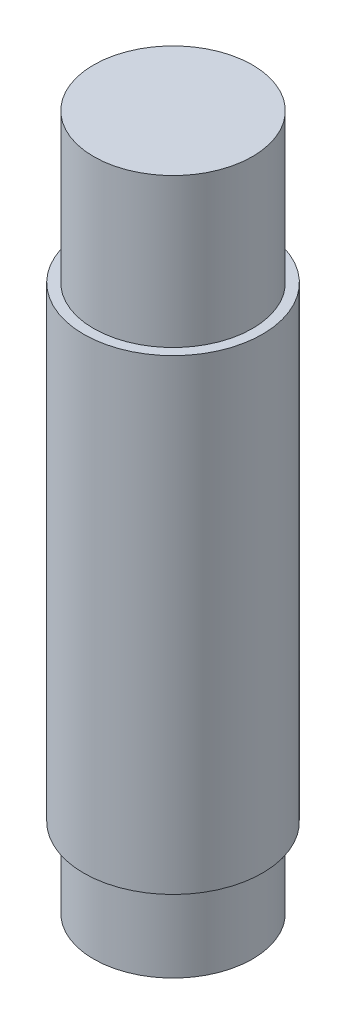
from build123d import *

# Parameters (mm, degrees)
SKETCH1_R           = 8
BOSS_EXTRUDE1_DEPTH = 8
SKETCH2_R           = 9
BOSS_EXTRUDE2_DEPTH = 47
SKETCH3_R           = 8
BOSS_EXTRUDE3_DEPTH = 15


with BuildPart() as part:
    # Sketch1 → Boss-Extrude1 (new body)
    with BuildSketch(Plane(origin=(0, 0, 0), x_dir=(1, 0, 0), z_dir=(0, 1, 0))):
        Circle(SKETCH1_R)
    extrude(amount=BOSS_EXTRUDE1_DEPTH)

    # Sketch2 → Boss-Extrude2 (add)
    with BuildSketch(Plane(origin=(0, 8, 0), x_dir=(1, 0, 0), z_dir=(0, 1, 0))):
        Circle(SKETCH2_R)
    extrude(amount=BOSS_EXTRUDE2_DEPTH)

    # Sketch3 → Boss-Extrude3 (add)
    with BuildSketch(Plane(origin=(0, 55, 0), x_dir=(1, 0, 0), z_dir=(0, 1, 0))):
        Circle(SKETCH3_R)
    extrude(amount=BOSS_EXTRUDE3_DEPTH)


solid = part.part
